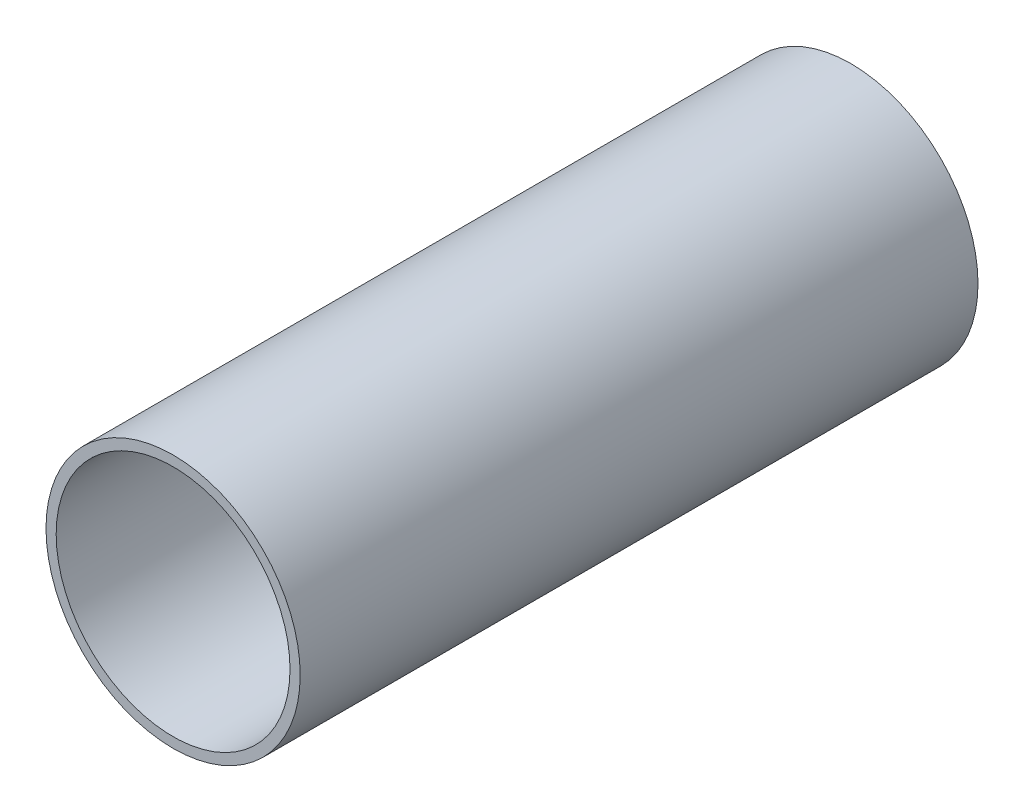
from build123d import *

# Parameters (mm, degrees)
SKIZZE1_R                    = 37.5
SKIZZE1_R_2                  = 34.5
LINEAR_AUSTRAGEN_D_NN1_DEPTH = 200


with BuildPart() as part:
    # Skizze1 → Linear-Austragen-Dünn1 (new body)
    with BuildSketch(Plane.XY):
        Circle(SKIZZE1_R)
        Circle(SKIZZE1_R_2, mode=Mode.SUBTRACT)
    extrude(amount=LINEAR_AUSTRAGEN_D_NN1_DEPTH)


solid = part.part
